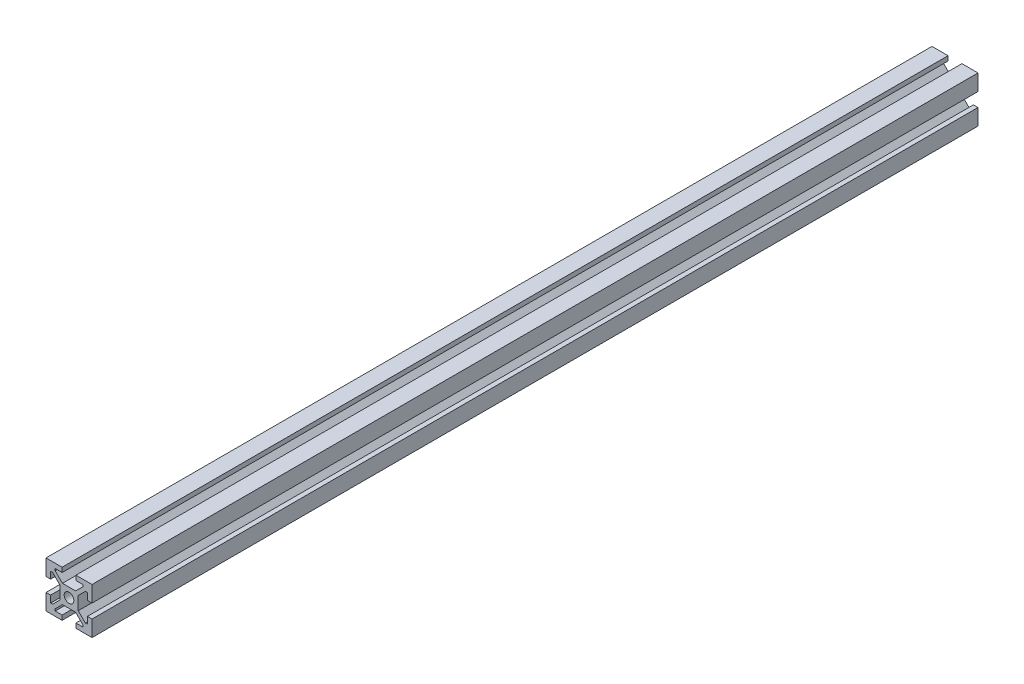
from build123d import *

# Parameters (mm, degrees)
CROQUIS1_R              = 2.1
SALIENTE_EXTRUIR2_DEPTH = 385


with BuildPart() as part:
    # Croquis1 → Saliente-Extruir2 (new body)
    with BuildSketch(Plane.XY):
        Polygon((-3, 10), (-3, 8), (-6, 8), (-6, 7.13), (-2.87, 4), (2.87, 4), (6, 7.13), (6, 8), (3, 8), (3, 10), (10, 10), (10, 3), (8, 3), (8, 6), (7.13, 6), (4, 2.87), (4, -2.87), (7.13, -6), (8, -6), (8, -3), (10, -3), (10, -10), (3, -10), (3, -8), (6, -8), (6, -7.13), (2.87, -4), (-2.87, -4), (-6, -7.13), (-6, -8), (-3, -8), (-3, -10), (-10, -10), (-10, -3), (-8, -3), (-8, -6), (-7.13, -6), (-4, -2.87), (-4, 2.87), (-7.13, 6), (-8, 6), (-8, 3), (-10, 3), (-10, 10), align=None)
        Circle(CROQUIS1_R, mode=Mode.SUBTRACT)
    extrude(amount=-SALIENTE_EXTRUIR2_DEPTH)


solid = part.part
